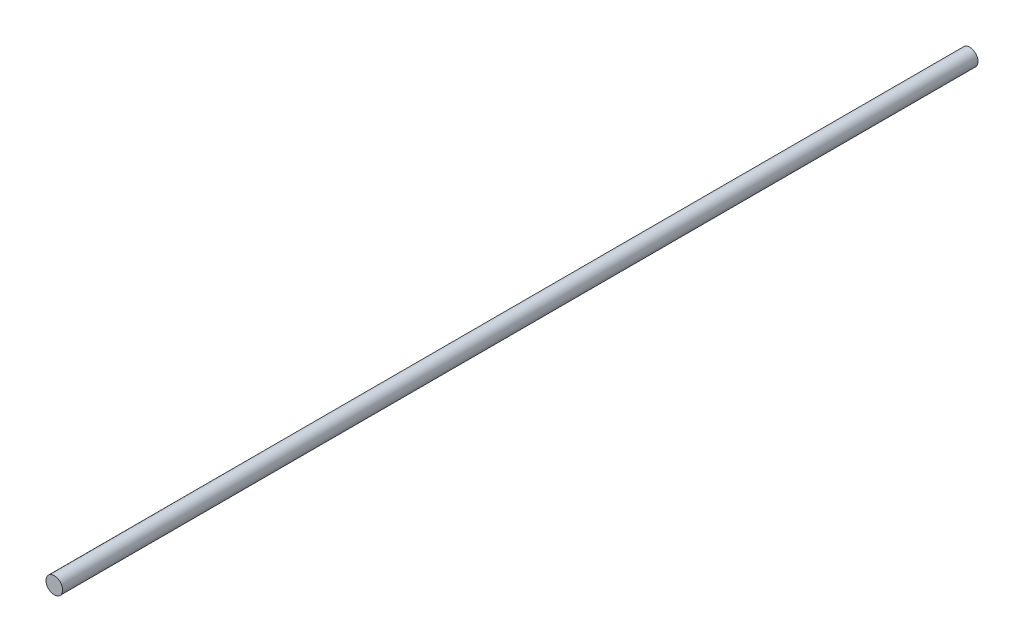
from build123d import *

# Parameters (mm, degrees)
IZIM1_R                     = 6
Y_KSEKLIK_EKSTR_ZYON1_DEPTH = 662


with BuildPart() as part:
    # Çizim1 → Yükseklik-Ekstrüzyon1 (new body)
    with BuildSketch(Plane.XY):
        Circle(IZIM1_R)
    extrude(amount=Y_KSEKLIK_EKSTR_ZYON1_DEPTH)


solid = part.part
